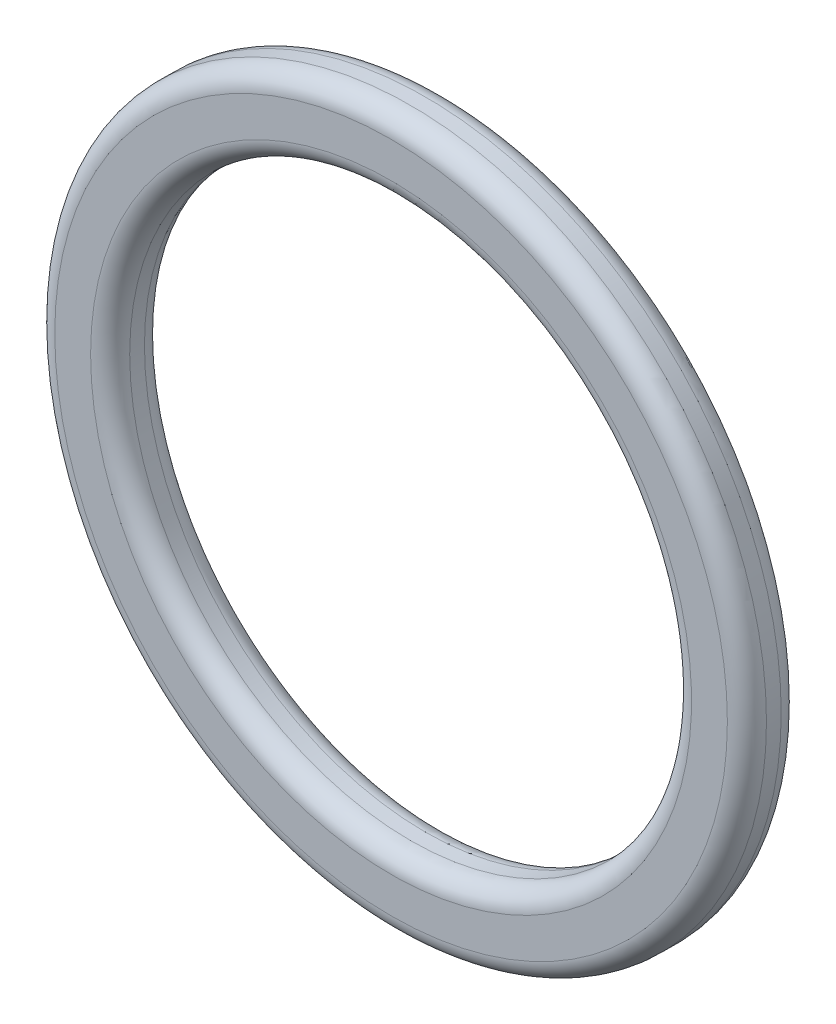
from build123d import *


with BuildPart() as part:
    # Sketch1 → Muokkautunut (revolve)
    with BuildSketch(Plane(origin=(0, 0, 0), x_dir=(0, 0, -1), z_dir=(1, 0, 0))):
        with BuildLine():
            Line((-1.465, 12), (-0.835, 12))
            ThreePointArc((-0.835, 12), (-0.244565838, 12.244565838), (0, 12.835))
            Line((0, 12.835), (0, 14.365))
            ThreePointArc((0, 14.365), (-0.244565838, 14.955434162), (-0.835, 15.2))
            Line((-0.835, 15.2), (-1.465, 15.2))
            ThreePointArc((-1.465, 15.2), (-2.055434162, 14.955434162), (-2.3, 14.365))
            Line((-2.3, 14.365), (-2.3, 12.835))
            ThreePointArc((-2.3, 12.835), (-2.055434162, 12.244565838), (-1.465, 12))
        make_face()
    revolve(axis=Axis((0, 0, 0), (0, 0, 1)))


solid = part.part
